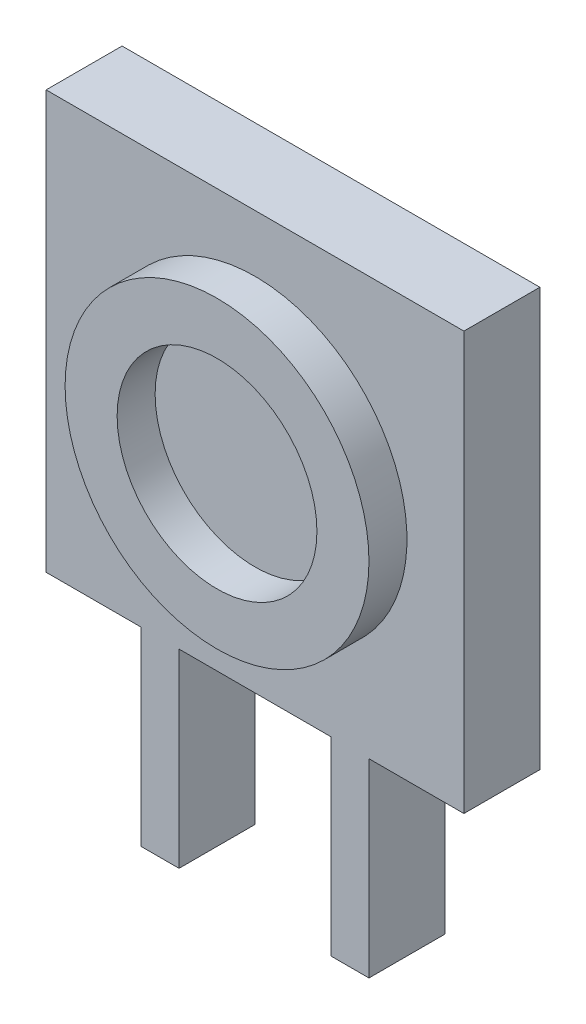
from build123d import *

# Parameters (mm, degrees)
EXTRUDE1_DEPTH = 2
SKETCH2_R      = 4
SKETCH2_R_2    = 2.63
EXTRUDE2_DEPTH = 1


with BuildPart() as part:
    # Sketch1 → Extrude1 (new body)
    with BuildSketch(Plane.XY):
        Polygon((-2, -5.5), (2, -5.5), (2, -10.5), (3, -10.5), (3, -5.5), (5.5, -5.5), (5.5, 5.5), (-5.5, 5.5), (-5.5, -5.5), (-3, -5.5), (-3, -10.5), (-2, -10.5), align=None)
    extrude(amount=EXTRUDE1_DEPTH)

    # Sketch2 → Extrude2 (add)
    with BuildSketch(Plane.XY.offset(2)):
        with Locations(Location((0, 0, 0), (0, 0, 180))):  # turned: the seam where the file's is
            Circle(SKETCH2_R)
        Circle(SKETCH2_R_2, mode=Mode.SUBTRACT)
    extrude(amount=EXTRUDE2_DEPTH)


solid = part.part
